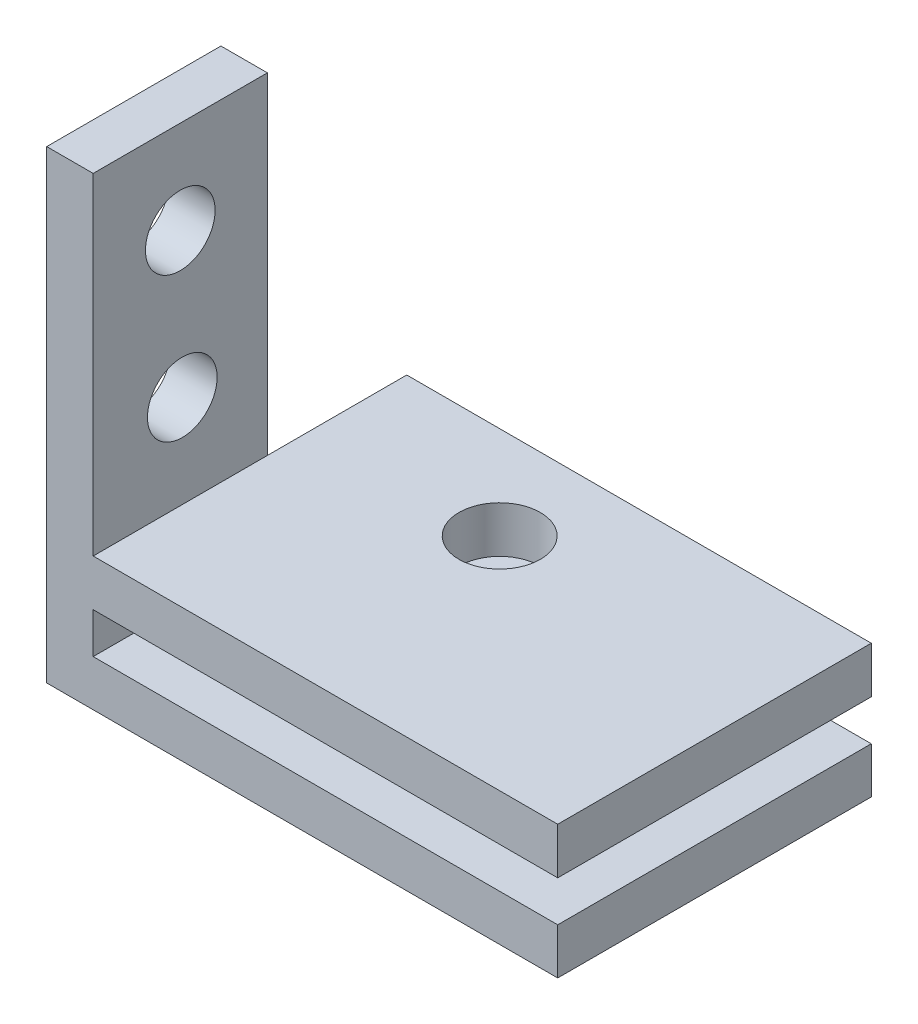
from build123d import *

# Parameters (mm, degrees)
SKETCH1_W           = 7.5
SKETCH1_H           = 20
BOSS_EXTRUDE2_DEPTH = 2
SKETCH2_W           = 7.5
SKETCH2_H           = 1.98347932
BOSS_EXTRUDE3_DEPTH = 20
SKETCH3_W           = 7.5
SKETCH3_H           = 2
BOSS_EXTRUDE4_DEPTH = 20
SKETCH5_R           = 1.5
CUT_EXTRUDE1_DEPTH  = 20
SKETCH7_W           = 20
SKETCH7_H           = 2
BOSS_EXTRUDE6_DEPTH = 6
SKETCH8_W           = 20
SKETCH8_H           = 1.98347932
BOSS_EXTRUDE7_DEPTH = 6
SKETCH9_R           = 1.75
CUT_EXTRUDE2_DEPTH  = 6


with BuildPart() as part:
    # Sketch1 → Boss-Extrude2 (new body)
    with BuildSketch(Plane(origin=(0, 0, 0), x_dir=(0, 0, -1), z_dir=(1, 0, 0))):
        with Locations((3.009581882, -0.975609756)):
            Rectangle(SKETCH1_W, SKETCH1_H)
    extrude(amount=BOSS_EXTRUDE2_DEPTH)

    # Sketch2 → Boss-Extrude3 (add)
    with BuildSketch(Plane(origin=(2, 0, 0), x_dir=(0, 0, -1), z_dir=(1, 0, 0))):
        with Locations((3.009581882, -9.983870096)):
            Rectangle(SKETCH2_W, SKETCH2_H)
    extrude(amount=BOSS_EXTRUDE3_DEPTH)

    # Sketch3 → Boss-Extrude4 (add)
    with BuildSketch(Plane(origin=(2, 0, 0), x_dir=(0, 0, -1), z_dir=(1, 0, 0))):
        with Locations((3.009581882, -6.242130436)):
            Rectangle(SKETCH3_W, SKETCH3_H)
    extrude(amount=BOSS_EXTRUDE4_DEPTH)

    # Sketch5 → Cut-Extrude1 (cut)
    with BuildSketch(Plane(origin=(2, 0, 0), x_dir=(0, 0, -1), z_dir=(1, 0, 0))):
        with Locations((3.009581882, 5.024390244)):
            Circle(SKETCH5_R)
        with Locations((3.096458319, -1.242130436)):
            Circle(SKETCH5_R)
    extrude(amount=-CUT_EXTRUDE1_DEPTH, mode=Mode.SUBTRACT)

    # Sketch7 → Boss-Extrude6 (add)
    with BuildSketch(Plane(origin=(0, 0, -6.759581882), x_dir=(-1, 0, 0), z_dir=(0, 0, -1))):
        with Locations((-12, -6.242130436)):
            Rectangle(SKETCH7_W, SKETCH7_H)
    extrude(amount=BOSS_EXTRUDE6_DEPTH)

    # Sketch8 → Boss-Extrude7 (add)
    with BuildSketch(Plane(origin=(0, 0, -6.759581882), x_dir=(-1, 0, 0), z_dir=(0, 0, -1))):
        with Locations((-12, -9.983870096)):
            Rectangle(SKETCH8_W, SKETCH8_H)
    extrude(amount=BOSS_EXTRUDE7_DEPTH)

    # Sketch9 → Cut-Extrude2 (cut)
    with BuildSketch(Plane(origin=(0, -5.242130436, 0), x_dir=(1, 0, 0), z_dir=(0, 1, 0))):
        with Locations((10, 8.759581882)):
            Circle(SKETCH9_R)
    extrude(amount=-CUT_EXTRUDE2_DEPTH, mode=Mode.SUBTRACT)


solid = part.part
